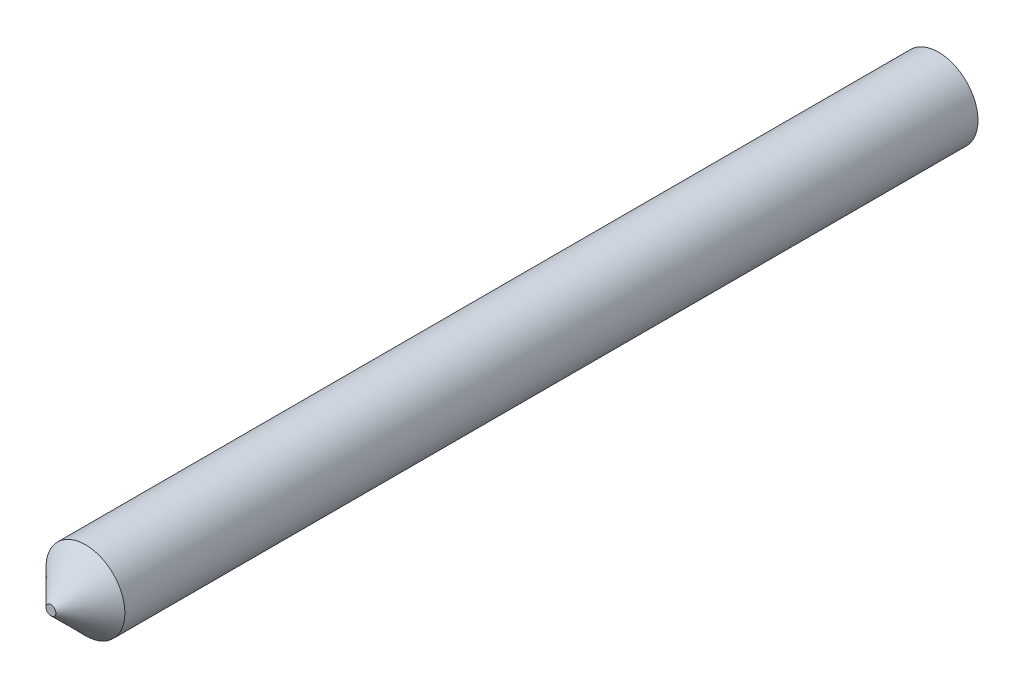
from build123d import *

# Parameters (mm, degrees)
SKETCH1_R           = 2
BOSS_EXTRUDE1_DEPTH = 45
CHAMFER1_SIZE       = 1.75


with BuildPart() as part:
    # Sketch1 → Boss-Extrude1 (new body)
    with BuildSketch(Plane.XY):
        Circle(SKETCH1_R)
    extrude(amount=BOSS_EXTRUDE1_DEPTH)

    # Chamfer1
    chamfer1_edges = [part.edges().sort_by_distance(p)[0] for p in [
        (-2, 0, 45),
    ]]
    chamfer(chamfer1_edges, length=CHAMFER1_SIZE)


solid = part.part
